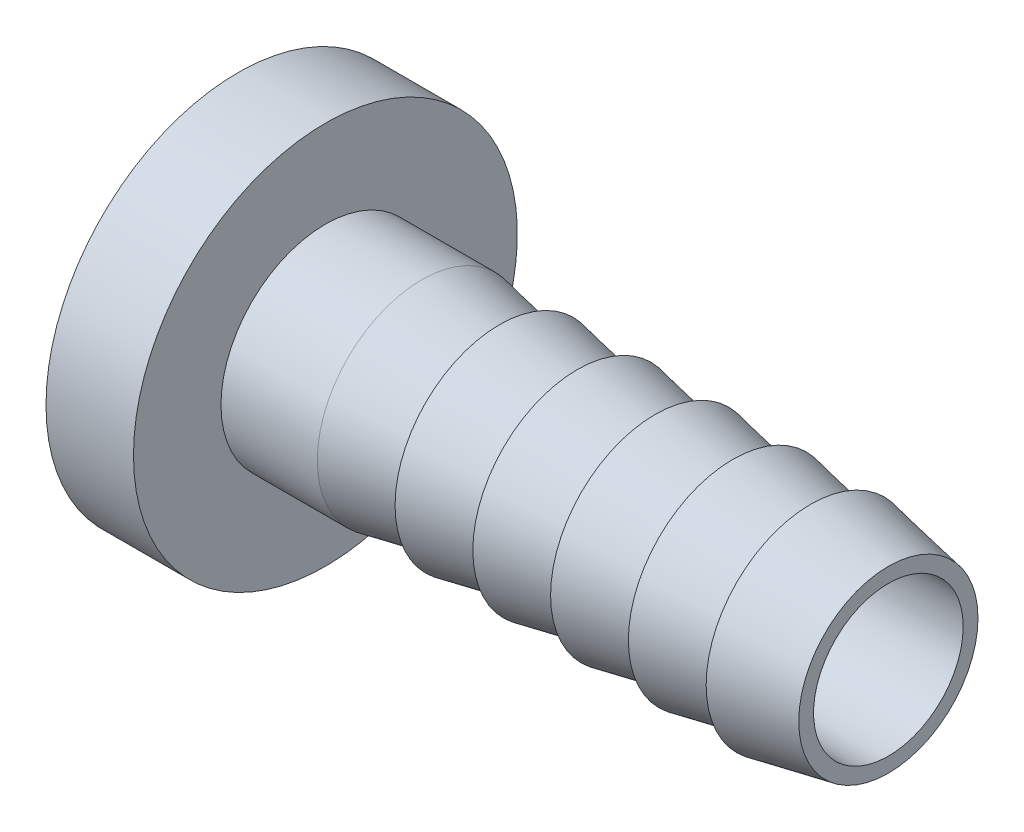
from build123d import *

# Parameters (mm, degrees)
EXTRUDE1_DEPTH         = 6.477
SKETCH3_OUTSIDE_W      = 44.89
SKETCH3_OUTSIDE_H      = 47.346
SKETCH3_OUTSIDE_R      = 7.9375
CUT_EXTRUDE1_DEPTH     = 6.35
CUT_EXTRUDE1_DRAFT     = -60
SKETCH4_OUTSIDE_W      = 44.891
SKETCH4_OUTSIDE_H      = 47.346
SKETCH4_OUTSIDE_R      = 7.9375
CUT_EXTRUDE2_DEPTH     = 6.35
CUT_EXTRUDE2_DRAFT     = -60
SKETCH6_W              = 19.304
SKETCH6_H              = 3.5814
LPATTERN1_COUNT        = 6
LPATTERN1_PITCH        = 2.667
EXTRUDE2_REACH         = 45.385
SKETCH8_R              = 7.9375
CUT_SWEEP1_PITCH       = 1.411111111
CUT_SWEEP1_HEIGHT      = 25.4
CUT_SWEEP1_RADIUS      = 7.9375
CUT_SWEEP1_START_ANGLE = -90
SKETCH13_R             = 4.988956448
CUT_EXTRUDE3_DEPTH     = 20.32
SKETCH14_R             = 2.5654
CUT_EXTRUDE4_DEPTH     = 21.336
CUT_EXTRUDE5_REACH     = 30.859
SKETCH15_W             = 22.352
SKETCH15_H             = 18.330871046
SKETCH16_R             = 6.5814
SKETCH16_R_2           = 2.5654
BOSS_EXTRUDE1_DEPTH    = 3


with BuildPart() as part:
    # Sketch2 → Extrude1 (new body)
    with BuildSketch(Plane(origin=(-4.953, 0, 0), x_dir=(0, 0, -1), z_dir=(1, 0, 0))):
        Polygon((0, 9.165435523), (-7.9375, 4.582717762), (-7.9375, -4.582717762), (0, -9.165435523), (7.9375, -4.582717762), (7.9375, 4.582717762), align=None)
    extrude(amount=EXTRUDE1_DEPTH)


with BuildPart() as cut_extrude1_tool:
    # Sketch3 outside → Cut-Extrude1 (with draft: the straight prism first)
    with BuildSketch(Plane(origin=(1.524, 0, 0), x_dir=(0, 0, -1), z_dir=(1, 0, 0))):
        Rectangle(SKETCH3_OUTSIDE_W, SKETCH3_OUTSIDE_H)
        Circle(SKETCH3_OUTSIDE_R, mode=Mode.SUBTRACT)
    extrude(amount=-CUT_EXTRUDE1_DEPTH)
    # Cut-Extrude1: the draft: its side faces are tilted about the plane it starts from
    cut_extrude1_sides = [cut_extrude1_tool.faces().sort_by_distance(p)[0] for p in [
        (-1.651, -23.673, 0),
        (-1.651, 0, -22.445),
        (-1.651, 23.673, 0),
        (-1.651, 0, 22.445),
        (-1.651, 0, 7.9375),
    ]]
    draft(cut_extrude1_sides, Plane(origin=(1.524, 0, 0), x_dir=(0, 0, -1), z_dir=(1, 0, 0)), CUT_EXTRUDE1_DRAFT)


with BuildPart() as part_1:
    add(part.part)

    # Cut-Extrude1: cut by cut_extrude1_tool
    add(cut_extrude1_tool.part, mode=Mode.SUBTRACT)


with BuildPart() as cut_extrude2_tool:
    # Sketch4 outside → Cut-Extrude2 (with draft: the straight prism first)
    with BuildSketch(Plane.ZY.offset(4.953)):
        with Locations((-0.0005, 0)):
            Rectangle(SKETCH4_OUTSIDE_W, SKETCH4_OUTSIDE_H)
        Circle(SKETCH4_OUTSIDE_R, mode=Mode.SUBTRACT)
    extrude(amount=-CUT_EXTRUDE2_DEPTH)
    # Cut-Extrude2: the draft: its side faces are tilted about the plane it starts from
    cut_extrude2_sides = [cut_extrude2_tool.faces().sort_by_distance(p)[0] for p in [
        (-1.778, -23.673, -0.0005),
        (-1.778, 0, 22.445),
        (-1.778, 23.673, -0.0005),
        (-1.778, 0, -22.446),
        (-1.778, 0, -7.9375),
    ]]
    draft(cut_extrude2_sides, Plane.ZY.offset(4.953), CUT_EXTRUDE2_DRAFT)


with BuildPart() as part_2:
    add(part_1.part)

    # Cut-Extrude2: cut by cut_extrude2_tool
    add(cut_extrude2_tool.part, mode=Mode.SUBTRACT)

    # Sketch6 → Revolve1 (revolve)
    with BuildSketch(Plane.XY, mode=Mode.PRIVATE) as revolve1_sk:
        with Locations((11.176, 1.7907)):
            Rectangle(SKETCH6_W, SKETCH6_H)
    revolve(revolve1_sk.sketch.rotate(Axis((0, 0, 0), (-1, 0, 0)), 90), axis=Axis((0, 0, 0), (-1, 0, 0)))

    # Sketch7 → Cut-Revolve1 (revolve, cut)
    with BuildSketch(Plane.XY, mode=Mode.PRIVATE) as cut_revolve1_sk:
        Polygon((18.161, 3.5814), (20.828, 3.5814), (20.828, 3.0734), align=None)
    cut_revolve1 = revolve(cut_revolve1_sk.sketch.rotate(Axis((-20.828, 0, 0), (1, 0, 0)), 270), axis=Axis((-20.828, 0, 0), (1, 0, 0)), mode=Mode.SUBTRACT)

    # LPattern1: Cut-Revolve1 ×6
    with Locations(*[(-i * LPATTERN1_PITCH, 0, 0) for i in range(1, LPATTERN1_COUNT)]):
        add(cut_revolve1, mode=Mode.SUBTRACT)


with BuildPart() as body_2:

    # Sketch8 → Extrude2 (new, up to next)
    with BuildSketch(Plane(origin=(-20.828, 0, 0), x_dir=(0, 0, -1), z_dir=(1, 0, 0)), mode=Mode.PRIVATE) as extrude2_sk1:
        Circle(SKETCH8_R)
    extrude2_tool1 = extrude(extrude2_sk1.sketch, amount=EXTRUDE2_REACH, mode=Mode.PRIVATE) - part_2.part
    add(extrude2_tool1.solids().sort_by_distance((-20.828, 0, 0))[0])

    # Sketch11 → Cut-Revolve2 (revolve, cut)
    with BuildSketch(Plane.XY, mode=Mode.PRIVATE) as cut_revolve2_sk:
        Polygon((-4.953, 8.81327095), (-4.953, 7.020956448), (-7.3152, 7.020956448), (-9.107514503, 8.81327095), align=None)
        Polygon((-16.8656, 7.020956448), (-19.558, 7.020956448), (-20.828, 5.750956448), (-22.062722222, 5.750956448), (-22.062722222, 8.81327095), (-15.073285497, 8.81327095), align=None)
    revolve(cut_revolve2_sk.sketch.rotate(Axis((-20.828, 0, 0), (1, 0, 0)), 90), axis=Axis((-20.828, 0, 0), (1, 0, 0)), mode=Mode.SUBTRACT)


with BuildPart() as part_3:
    add(part_2.part)

    # Cut-Sweep1: sweep along a helix
    with BuildLine() as cut_sweep1_path:
        add(Helix(CUT_SWEEP1_PITCH, CUT_SWEEP1_HEIGHT, CUT_SWEEP1_RADIUS, center=(-20.828, 0, 0), direction=(1, 0, 0), mode=Mode.PRIVATE).rotate(Axis((-20.828, 0, 0), (1, 0, 0)), CUT_SWEEP1_START_ANGLE))
    # Sketch10 → Cut-Sweep1 (sweep, cut)
    with BuildSketch(Plane.XY):
        Polygon((-22.062722222, 7.9375), (-21.533555556, 7.020956448), (-21.357166667, 7.020956448), (-20.828, 7.9375), (-20.762314311, 8.05127095), align=None)
    sweep(path=cut_sweep1_path.line, is_frenet=True, mode=Mode.SUBTRACT)


with BuildPart() as body_2_1:
    add(body_2.part)

    # Combine1: union part
    add(part_3.part)

    # Sketch13 → Cut-Extrude3 (cut)
    with BuildSketch(Plane.ZY.offset(20.828)):
        Circle(SKETCH13_R)
    extrude(amount=-CUT_EXTRUDE3_DEPTH, mode=Mode.SUBTRACT)

    # Sketch14 → Cut-Extrude4 (cut)
    with BuildSketch(Plane(origin=(20.828, 0, 0), x_dir=(0, 0, -1), z_dir=(1, 0, 0))):
        Circle(SKETCH14_R)
    extrude(amount=-CUT_EXTRUDE4_DEPTH, mode=Mode.SUBTRACT)

    # Sketch15 → Cut-Extrude5 (cut, up to next)
    with BuildSketch(Plane(origin=(0, 6.874076643, -3.96875), x_dir=(1, 0, 0), z_dir=(0, 0.8660254037844387, -0.4999999999999999)), mode=Mode.PRIVATE) as cut_extrude5_sk1:
        with Locations((-9.652, 0)):
            Rectangle(SKETCH15_W, SKETCH15_H)
    cut_extrude5_tool1 = extrude(cut_extrude5_sk1.sketch, amount=-CUT_EXTRUDE5_REACH, mode=Mode.PRIVATE) & body_2_1.part
    add(cut_extrude5_tool1.solids().sort_by_distance((-9.652, 6.874077, -3.96875))[0], mode=Mode.SUBTRACT)

    # Sketch16 → Boss-Extrude1 (add)
    with BuildSketch(Plane.ZY.offset(-1.524)):
        Circle(SKETCH16_R)
        with Locations(Location((0, 0, 0), (0, 0, 180))):
            Circle(SKETCH16_R_2, mode=Mode.SUBTRACT)
    extrude(amount=BOSS_EXTRUDE1_DEPTH)


solid = body_2_1.part
